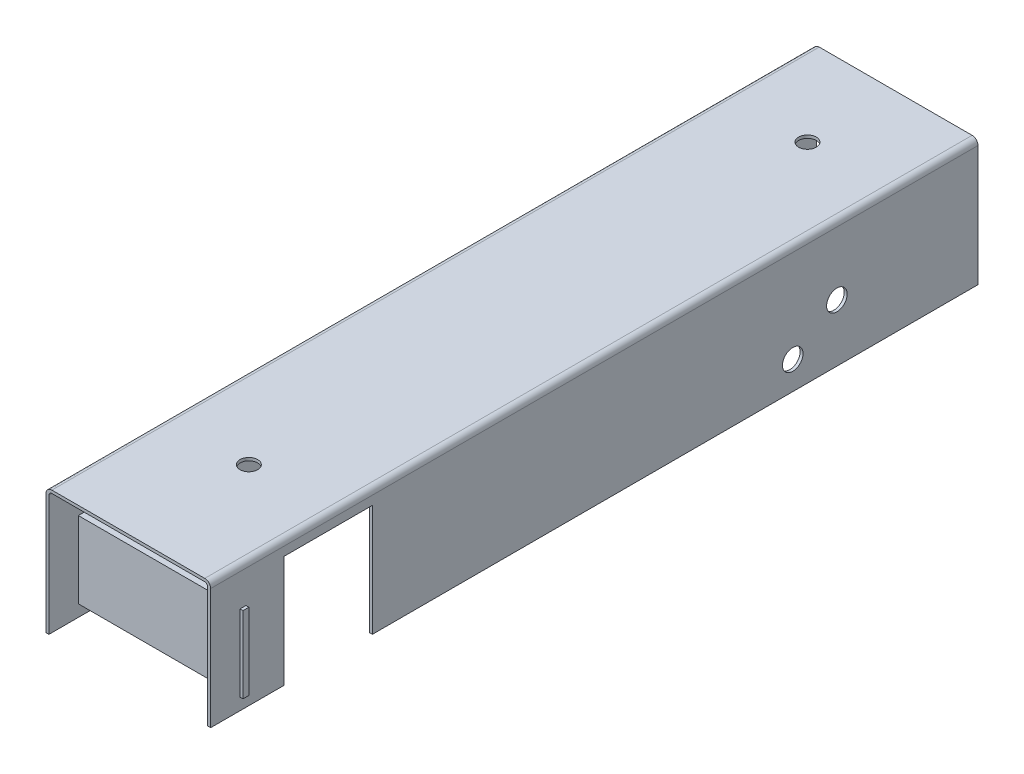
from build123d import *

# Parameters (mm, degrees)
BOSS_EXTRUDE1_DEPTH      = 261
FILLET1_R                = 2
FILLET2_R                = 1
BOSS_EXTRUDE2_DEPTH      = 56
BOSS_EXTRUDE2_DEPTH_BACK = 2
SKETCH2_W                = 2
SKETCH2_H                = 26
SKETCH3_R                = 3
CUT_EXTRUDE1_DEPTH       = 11
SKETCH4_W                = 30
SKETCH4_H                = 40
CUT_EXTRUDE2_DEPTH       = 10
SKETCH5_R                = 3.5
CUT_EXTRUDE3_DEPTH       = 76


with BuildPart() as part:
    # Sketch1 → Boss-Extrude1 (new body)
    with BuildSketch(Plane.XY):
        Polygon((27, -21.5), (27, -20.5), (27, 20.5), (-27, 20.5), (-27, -20.5), (-27, -21.5), (-28, -21.5), (-28, 21.5), (28, 21.5), (28, -21.5), align=None)
    extrude(amount=BOSS_EXTRUDE1_DEPTH)

    # Fillet1
    fillet1_edges = [part.edges().sort_by_distance(p)[0] for p in [
        (-28, 21.5, 130.5),
        (28, 21.5, 130.5),
    ]]
    fillet(fillet1_edges, radius=FILLET1_R)

    # Fillet2
    fillet2_edges = [part.edges().sort_by_distance(p)[0] for p in [
        (27, 20.5, 130.5),
        (-27, 20.5, 130.5),
    ]]
    fillet(fillet2_edges, radius=FILLET2_R)

    # Sketch2 → Boss-Extrude2 (add, two sides: drawn at the far end of the back side and taken through both)
    with BuildSketch(Plane(origin=(-27, 0, 0), x_dir=(0, 0, -1), z_dir=(1, 0, 0)).offset(-BOSS_EXTRUDE2_DEPTH_BACK)):
        with Locations((-250, -4.5)):
            Rectangle(SKETCH2_W, SKETCH2_H)
    extrude(amount=BOSS_EXTRUDE2_DEPTH + BOSS_EXTRUDE2_DEPTH_BACK)

    # Sketch3 → Cut-Extrude1 (cut)
    with BuildSketch(Plane(origin=(0, 21.5, 0), x_dir=(1, 0, 0), z_dir=(0, 1, 0))):
        with Locations(Location((0, -30, 0), (0, 0, 270))):
            Circle(SKETCH3_R)
        with Locations(Location((0, -220, 0), (0, 0, 270))):
            Circle(SKETCH3_R)
    extrude(amount=-CUT_EXTRUDE1_DEPTH, mode=Mode.SUBTRACT)

    # Sketch4 → Cut-Extrude2 (cut)
    with BuildSketch(Plane(origin=(28, 0, 0), x_dir=(0, 0, -1), z_dir=(1, 0, 0))):
        with Locations((-221, -3.5)):
            Rectangle(SKETCH4_W, SKETCH4_H)
    extrude(amount=-CUT_EXTRUDE2_DEPTH, mode=Mode.SUBTRACT)

    # Sketch5 → Cut-Extrude3 (cut)
    with BuildSketch(Plane(origin=(28, 0, 0), x_dir=(0, 0, -1), z_dir=(1, 0, 0))):
        with Locations(Location((-48, -2, 0), (0, 0, 90))):
            Circle(SKETCH5_R)
        with Locations(Location((-63, -12, 0), (0, 0, 90))):
            Circle(SKETCH5_R)
    extrude(amount=-CUT_EXTRUDE3_DEPTH, mode=Mode.SUBTRACT)


solid = part.part
